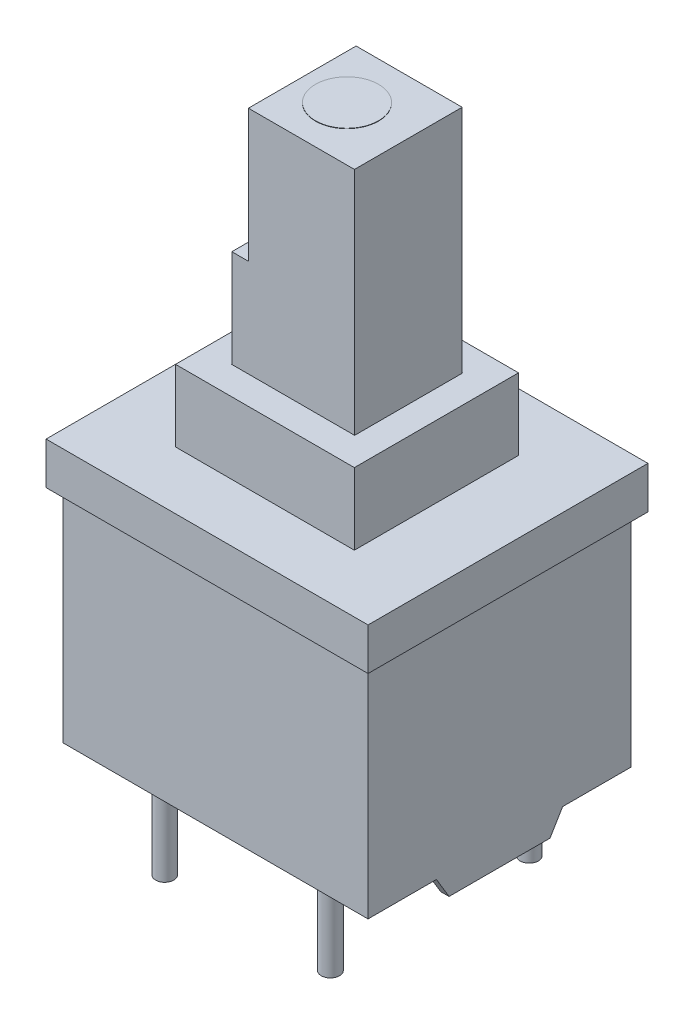
from build123d import *

# Parameters (mm, degrees)
SKETCH1_W           = 9.2075
SKETCH1_H           = 7.9375
BOSS_EXTRUDE1_DEPTH = 7.9375
SKETCH2_W           = 5.3975
SKETCH2_H           = 4.953
BOSS_EXTRUDE2_DEPTH = 2.159
SKETCH3_W           = 3.72
SKETCH3_H           = 3.26
CUT_EXTRUDE1_DEPTH  = 1.778
SKETCH4_W           = 9.7155
SKETCH4_H           = 8.4455
SKETCH4_W_2         = 5.3975
SKETCH4_H_2         = 4.953
BOSS_EXTRUDE3_DEPTH = 1.27
BOSS_EXTRUDE4_DEPTH = 0.254
SKETCH7_W           = 3.7
SKETCH7_H           = 3.25
BOSS_EXTRUDE6_DEPTH = 8.72
SKETCH8_W           = 0.5
SKETCH8_H           = 3.25
CUT_EXTRUDE2_DEPTH  = 4
SKETCH6_R           = 0.9525
BOSS_EXTRUDE5_DEPTH = 8.73
SKETCH9_R           = 0.275
BOSS_EXTRUDE7_DEPTH = 2.885


with BuildPart() as part:
    # Sketch1 → Boss-Extrude1 (new body)
    with BuildSketch(Plane(origin=(0, 0, 0), x_dir=(1, 0, 0), z_dir=(0, 1, 0))):
        Rectangle(SKETCH1_W, SKETCH1_H)
    extrude(amount=BOSS_EXTRUDE1_DEPTH)

    # Sketch2 → Boss-Extrude2 (add)
    with BuildSketch(Plane(origin=(0, 7.9375, 0), x_dir=(1, 0, 0), z_dir=(0, 1, 0))):
        Rectangle(SKETCH2_W, SKETCH2_H)
    extrude(amount=BOSS_EXTRUDE2_DEPTH)

    # Sketch3 → Cut-Extrude1 (cut)
    with BuildSketch(Plane(origin=(0, 10.0965, 0), x_dir=(1, 0, 0), z_dir=(0, 1, 0))):
        Rectangle(SKETCH3_W, SKETCH3_H)
    extrude(amount=-CUT_EXTRUDE1_DEPTH, mode=Mode.SUBTRACT)

    # Sketch4 → Boss-Extrude3 (add)
    with BuildSketch(Plane(origin=(0, 7.9375, 0), x_dir=(1, 0, 0), z_dir=(0, 1, 0))):
        Rectangle(SKETCH4_W, SKETCH4_H)
        Rectangle(SKETCH4_W_2, SKETCH4_H_2, mode=Mode.SUBTRACT)
    extrude(amount=-BOSS_EXTRUDE3_DEPTH)

    # Sketch5 → Boss-Extrude4 (add)
    with BuildSketch(Plane(origin=(4.60375, 0, 0), x_dir=(0, 0, -1), z_dir=(1, 0, 0))):
        Polygon((1.524, -0.635), (1.905, 0), (-1.905, 0), (-1.524, -0.635), align=None)
    boss_extrude4 = extrude(amount=-BOSS_EXTRUDE4_DEPTH)

    # Mirror1: Boss-Extrude4 across plane
    add(boss_extrude4.mirror(Plane(origin=(0, 0, 0), x_dir=(0, 0, 1), z_dir=(1, 0, 0))))

    # Sketch7 → Boss-Extrude6 (add)
    with BuildSketch(Plane(origin=(0, 8.3185, 0), x_dir=(1, 0, 0), z_dir=(0, 1, 0))):
        Rectangle(SKETCH7_W, SKETCH7_H)
    extrude(amount=BOSS_EXTRUDE6_DEPTH)

    # Sketch8 → Cut-Extrude2 (cut)
    with BuildSketch(Plane(origin=(0, 17.0385, 0), x_dir=(1, 0, 0), z_dir=(0, 1, 0))):
        with Locations((-1.6, 0)):
            Rectangle(SKETCH8_W, SKETCH8_H)
    extrude(amount=-CUT_EXTRUDE2_DEPTH, mode=Mode.SUBTRACT)

    # Sketch6 → Boss-Extrude5 (add)
    with BuildSketch(Plane(origin=(0, 8.3185, 0), x_dir=(1, 0, 0), z_dir=(0, 1, 0))):
        Circle(SKETCH6_R)
    extrude(amount=BOSS_EXTRUDE5_DEPTH)

    # Sketch9 → Boss-Extrude7 (add)
    with BuildSketch(Plane.XZ):
        with Locations((-2.5, 3)):
            Circle(SKETCH9_R)
        with Locations((2.5, 3)):
            Circle(SKETCH9_R)
        with Locations((2.5, -3)):
            Circle(SKETCH9_R)
        with Locations((-2.5, -3)):
            Circle(SKETCH9_R)
    extrude(amount=BOSS_EXTRUDE7_DEPTH)


solid = part.part
